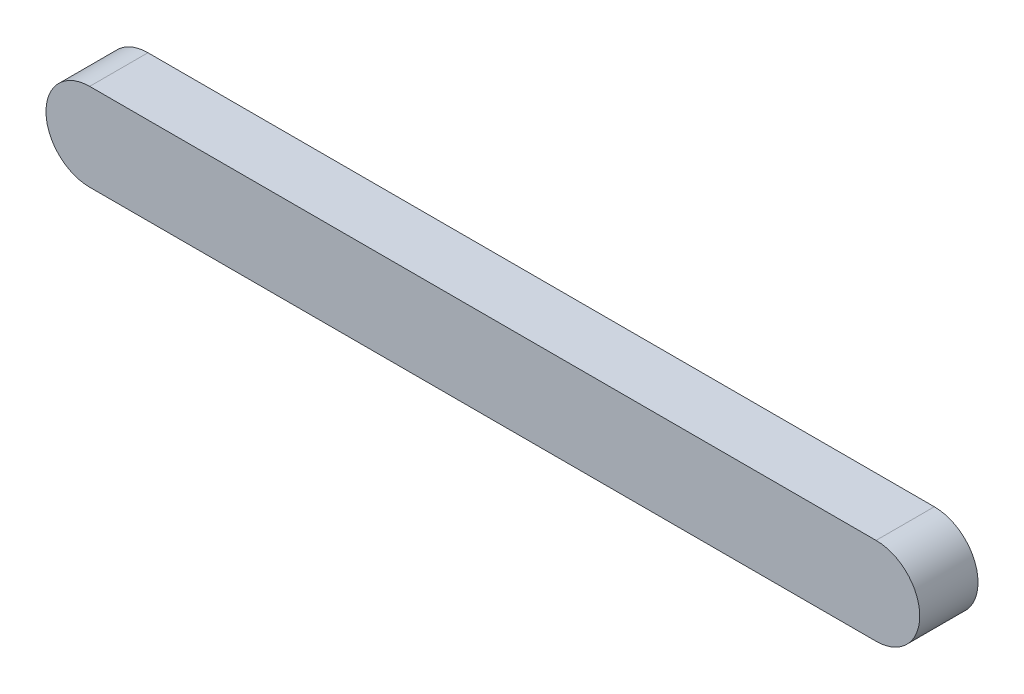
from build123d import *

# Parameters (mm, degrees)
EXTRUDE_1_DEPTH = 10


with BuildPart() as part:
    # 草图1 → 凸台-拉伸1 (new body)
    with BuildSketch(Plane.XY):
        with BuildLine():
            Line((0, -7.5), (-135, -7.5))
            ThreePointArc((-135, -7.5), (-142.5, 0), (-135, 7.5))
            Line((-135, 7.5), (0, 7.5))
            ThreePointArc((0, 7.5), (7.5, 0), (0, -7.5))
        make_face()
    extrude(amount=EXTRUDE_1_DEPTH)


solid = part.part
